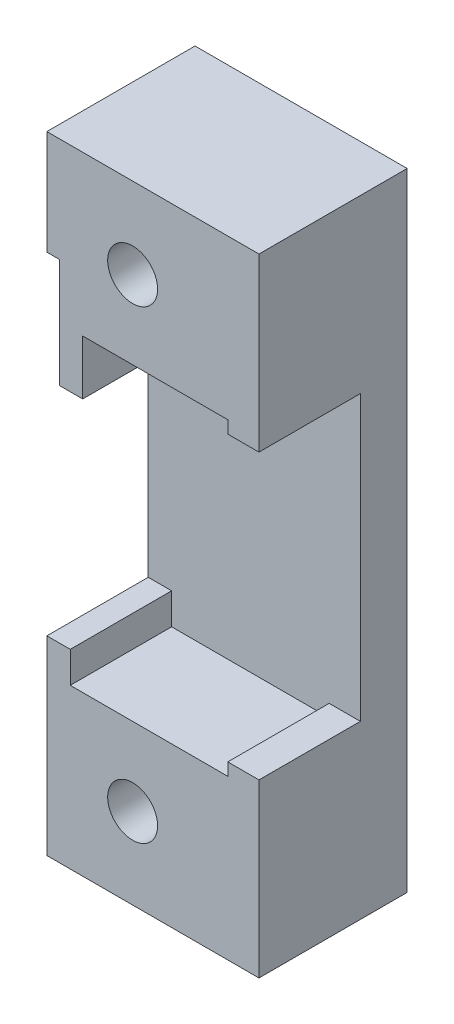
from build123d import *

# Parameters (mm, degrees)
SKETCH1_R               = 2.85
SKETCH1_R_2             = 1.6
BOSS_EXTRUDE1_DEPTH     = 6.5
SKETCH1_3_R             = 2.85
SKETCH1_3_R_2           = 1.6
BOSS_EXTRUDE2_DEPTH     = 3
CUT_EXTRUDE1_START      = -3
SKETCH1_4_R             = 2.85
CUT_EXTRUDE1_DEPTH      = 3.5
CUT_EXTRUDE1_DEPTH_BACK = 4


with BuildPart() as part:
    # Sketch1 → Boss-Extrude1 (new body)
    with BuildSketch(Plane(origin=(0, 0, 0), x_dir=(0, 1, 0), z_dir=(0, 0, 1))):
        Polygon((-7.9, 10.1), (-9.9, 10.1), (-9.9, 0), (-9.1, 0), (-9.1, -2), (-20.1, -2), (-20.1, 11.6), (-7.9, 11.6), align=None)
        with Locations((-14.9, 6.1)):
            Circle(SKETCH1_R, mode=Mode.SUBTRACT)
        Polygon((13.4, 11.6), (20.1, 11.6), (20.1, -2), (9.1, -2), (9.1, 0), (9.9, 0), (9.9, 9.3), (6.4, 9.3), (6.4, 10.8), (13.4, 10.8), align=None)
        with Locations((14.9, 6.1)):
            Circle(SKETCH1_R, mode=Mode.SUBTRACT)
        with Locations((-14.9, 6.1)):
            Circle(SKETCH1_R)
        with Locations((-14.9, 6.1)):
            Circle(SKETCH1_R_2, mode=Mode.SUBTRACT)
        with Locations((14.9, 6.1)):
            Circle(SKETCH1_R)
        with Locations((14.9, 6.1)):
            Circle(SKETCH1_R_2, mode=Mode.SUBTRACT)
    extrude(amount=BOSS_EXTRUDE1_DEPTH)

    # Sketch1_3 → Boss-Extrude2 (add)
    with BuildSketch(Plane(origin=(0, 0, 0), x_dir=(0, 1, 0), z_dir=(0, 0, 1))):
        with Locations((14.9, 6.1)):
            Circle(SKETCH1_3_R)
        with Locations((14.9, 6.1)):
            Circle(SKETCH1_3_R_2, mode=Mode.SUBTRACT)
        Polygon((13.4, 11.6), (20.1, 11.6), (20.1, -2), (9.1, -2), (9.1, 0), (9.9, 0), (9.9, 9.3), (6.4, 9.3), (6.4, 10.8), (13.4, 10.8), align=None)
        with Locations((14.9, 6.1)):
            Circle(SKETCH1_3_R, mode=Mode.SUBTRACT)
        Polygon((-7.9, 11.6), (13.4, 11.6), (13.4, 10.8), (6.4, 10.8), (6.4, 9.3), (9.9, 9.3), (9.9, 0), (9.1, 0), (9.1, -2), (-9.1, -2), (-9.1, 0), (-9.9, 0), (-9.9, 10.1), (-7.9, 10.1), align=None)
        with Locations((-14.9, 6.1)):
            Circle(SKETCH1_3_R)
        with Locations((-14.9, 6.1)):
            Circle(SKETCH1_3_R_2, mode=Mode.SUBTRACT)
        Polygon((-7.9, 10.1), (-9.9, 10.1), (-9.9, 0), (-9.1, 0), (-9.1, -2), (-20.1, -2), (-20.1, 11.6), (-7.9, 11.6), align=None)
        with Locations((-14.9, 6.1)):
            Circle(SKETCH1_3_R, mode=Mode.SUBTRACT)
    extrude(amount=-BOSS_EXTRUDE2_DEPTH)

    # Sketch1_4 → Cut-Extrude1 (cut, two sides)
    with BuildSketch(Plane(origin=(0, 0, 0), x_dir=(0, 1, 0), z_dir=(0, 0, 1)).offset(CUT_EXTRUDE1_START)) as cut_extrude1_sk:
        with Locations((14.9, 6.1)):
            Circle(SKETCH1_4_R)
        with Locations((-14.9, 6.1)):
            Circle(SKETCH1_4_R)
    extrude(amount=CUT_EXTRUDE1_DEPTH, mode=Mode.SUBTRACT)
    extrude(cut_extrude1_sk.sketch, amount=-CUT_EXTRUDE1_DEPTH_BACK, mode=Mode.SUBTRACT)


solid = part.part
